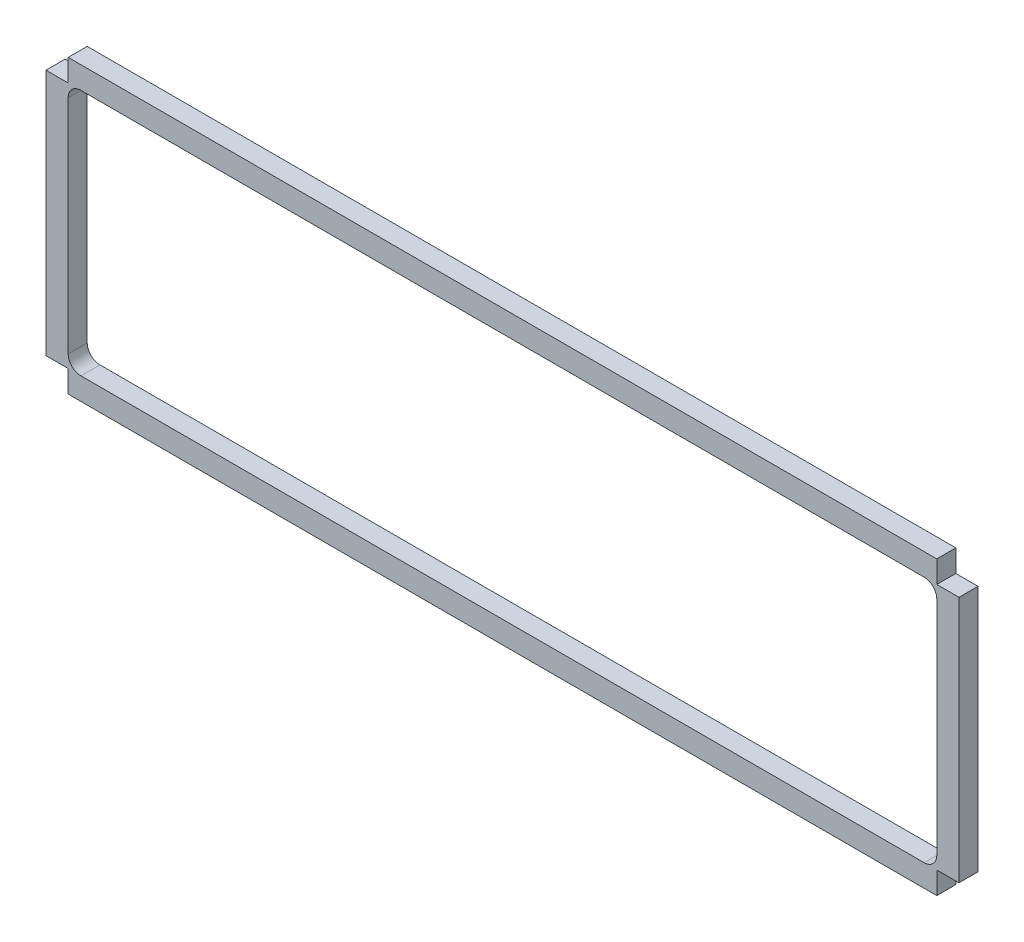
from build123d import *

# Parameters (mm, degrees)
BOSS_EXTRUDE1_DEPTH = 3
CUT_EXTRUDE3_DEPTH  = 3


with BuildPart() as part:
    # Sketch1 → Boss-Extrude1 (new body)
    with BuildSketch(Plane.XY):
        Polygon((68.5, 46), (-68.5, 46), (-68.5, 42.5), (-72, 42.5), (-72, 3.5), (-68.5, 3.5), (-68.5, 0), (68.5, 0), (68.5, 3.5), (72, 3.5), (72, 42.5), (68.5, 42.5), align=None)
    extrude(amount=BOSS_EXTRUDE1_DEPTH)

    # Sketch2 → Cut-Extrude3 (cut)
    with BuildSketch(Plane.XY.offset(3)):
        with BuildLine():
            Line((68.5, 5.5), (68.5, 40.5))
            ThreePointArc((68.5, 40.5), (67.914213562, 41.914213562), (66.5, 42.5))
            Line((66.5, 42.5), (-66.5, 42.5))
            ThreePointArc((-66.5, 42.5), (-67.914213562, 41.914213562), (-68.5, 40.5))
            Line((-68.5, 40.5), (-68.5, 5.5))
            ThreePointArc((-68.5, 5.5), (-67.914213562, 4.085786438), (-66.5, 3.5))
            Line((-66.5, 3.5), (66.5, 3.5))
            ThreePointArc((66.5, 3.5), (67.914213562, 4.085786438), (68.5, 5.5))
        make_face()
    extrude(amount=-CUT_EXTRUDE3_DEPTH, mode=Mode.SUBTRACT)


solid = part.part
